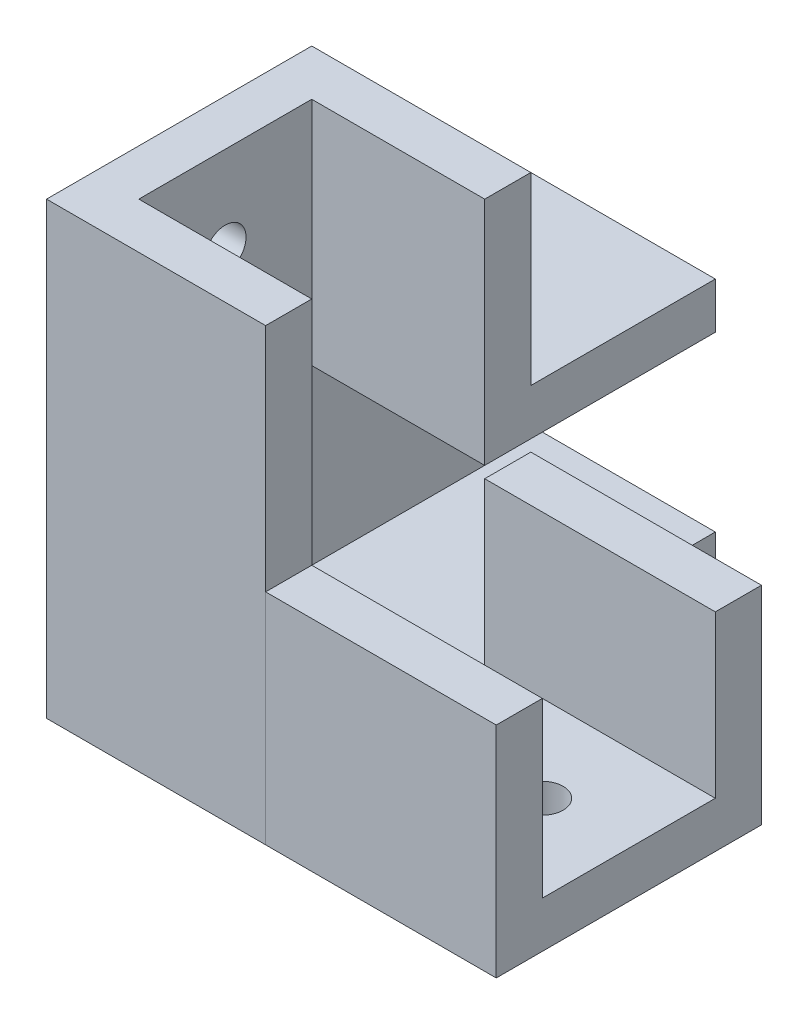
from build123d import *

# Parameters (mm, degrees)
SKETCH_1_W          = 4
SKETCH_1_H          = 19
SKETCH_1_W_2        = 15
SKETCH_1_H_2        = 4
EXTRUDE_1_DEPTH     = 15
SKETCH_2_W          = 19
SKETCH_2_H          = 19
EXTRUDE_2_DEPTH     = 4
EXTRUDE_3_DEPTH     = 20
EXTRUDE_5_DEPTH     = 20
EXTRUDE_6_DEPTH     = 20
SKETCH_7_W          = 19
SKETCH_7_H          = 4
EXTRUDE_7_DEPTH     = 16
SKETCH_8_R          = 1.8
CUT_EXTRUDE_1_DEPTH = 12
SKETCH_9_R          = 1.8
CUT_EXTRUDE_2_DEPTH = 12


with BuildPart() as part:
    # 草图1 → 凸台-拉伸1 (new body)
    with BuildSketch(Plane.XY):
        with Locations((-2, 9.5)):
            Rectangle(SKETCH_1_W, SKETCH_1_H)
        with Locations((7.5, 2)):
            Rectangle(SKETCH_1_W_2, SKETCH_1_H_2)
    extrude(amount=EXTRUDE_1_DEPTH)

    # 草图2 → 凸台-拉伸2 (add)
    with BuildSketch(Plane.XY.offset(15)):
        with Locations((5.5, 9.5)):
            Rectangle(SKETCH_2_W, SKETCH_2_H)
    extrude(amount=EXTRUDE_2_DEPTH)

    # 草图3 → 凸台-拉伸3 (add)
    with BuildSketch(Plane(origin=(0, 0, 0), x_dir=(-1, 0, 0), z_dir=(0, 0, -1))):
        Polygon((-15, 19), (0, 19), (0, 4), (-15, 4), (-15, 0), (4, 0), (4, 23), (-15, 23), align=None)
    extrude(amount=EXTRUDE_3_DEPTH)



with BuildPart() as body_2:
    # 草图5 → 凸台-拉伸5 (new body)
    with BuildSketch(Plane(origin=(15, 0, 0), x_dir=(0, 0, -1), z_dir=(1, 0, 0))):
        Polygon((-19, 0), (-15, 0), (0, 0), (4, 0), (4, 18), (0, 18), (0, 4), (-15, 4), (-15, 19), (-19, 19), align=None)
    extrude(amount=EXTRUDE_5_DEPTH)

    # 草图9 → 切除-拉伸2 (cut)
    with BuildSketch(Plane.XZ):
        with Locations((27.5, 7.5)):
            Circle(SKETCH_9_R)
    extrude(amount=-CUT_EXTRUDE_2_DEPTH, mode=Mode.SUBTRACT)


with BuildPart() as body_3:
    # 草图6 → 凸台-拉伸6 (new body)
    with BuildSketch(Plane(origin=(0, 19, 0), x_dir=(1, 0, 0), z_dir=(0, 1, 0))):
        Polygon((-4, -19), (15, -19), (15, -15), (0, -15), (0, 0), (-4, 0), (-4, -16), align=None)
    extrude(amount=EXTRUDE_6_DEPTH)


with BuildPart() as part_1:
    add(part.part)

    add(body_3.part)  # 凸台-拉伸7 merges body 3
    # 草图7 → 凸台-拉伸7 (add)
    with BuildSketch(Plane(origin=(0, 23, 0), x_dir=(1, 0, 0), z_dir=(0, 1, 0))):
        with Locations((5.5, 2)):
            Rectangle(SKETCH_7_W, SKETCH_7_H)
    extrude(amount=EXTRUDE_7_DEPTH)

    # 草图8 → 切除-拉伸1 (cut)
    with BuildSketch(Plane.ZY.offset(4)):
        with Locations((7.5, 31.5)):
            Circle(SKETCH_8_R)
        with Locations((-12.5, 10.5)):
            Circle(SKETCH_8_R)
    extrude(amount=-CUT_EXTRUDE_1_DEPTH, mode=Mode.SUBTRACT)


solid = Compound([body_2.part, part_1.part])
